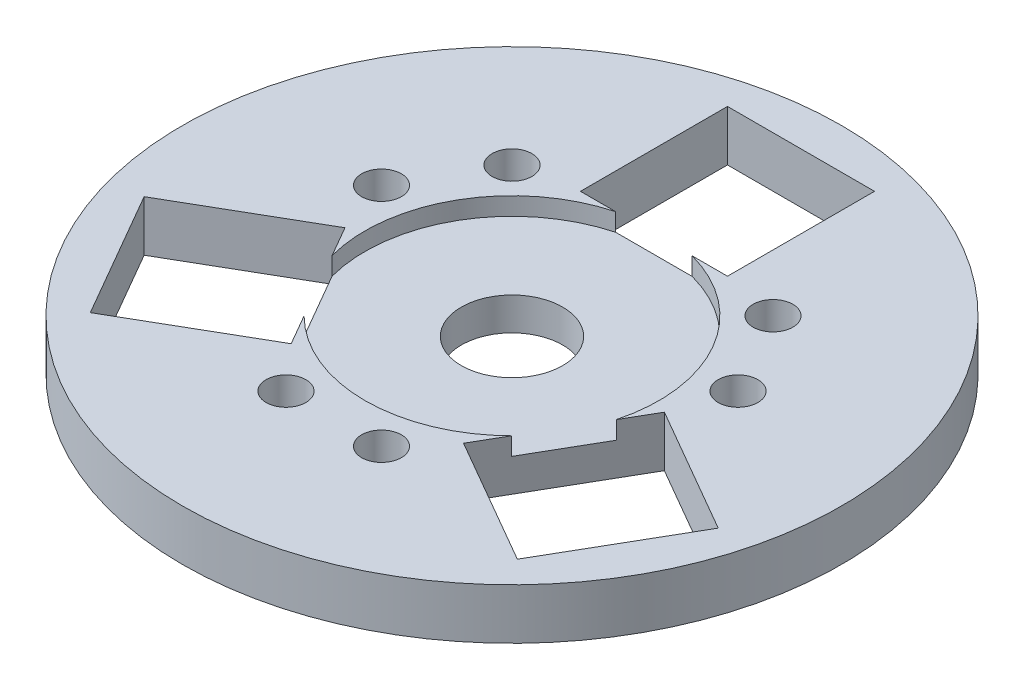
from build123d import *

# Parameters (mm, degrees)
SKETCH1_R           = 44.45
SKETCH1_R_2         = 6.35
BOSS_EXTRUDE1_DEPTH = 3.175
SKETCH5_W           = 18.415
SKETCH5_H           = 18.415
CUT_EXTRUDE4_DEPTH  = 64.181702256
CIRPATTERN2_COUNT   = 3
SKETCH3_R           = 44.45
SKETCH3_R_2         = 41.275
CUT_EXTRUDE2_DEPTH  = 64.181702256
SKETCH6_R           = 18.415
CUT_EXTRUDE5_DEPTH  = 2.2352
SKETCH7_R           = 2.4892
CUT_EXTRUDE6_DEPTH  = 59.716043378
CIRPATTERN3_COUNT   = 3


with BuildPart() as part:
    # Sketch1 → Boss-Extrude1 (new, symmetric)
    with BuildSketch(Plane(origin=(0, 0, 0), x_dir=(1, 0, 0), z_dir=(0, 1, 0))):
        with Locations(Location((0, 0, 0), (0, 0, 270))):
            Circle(SKETCH1_R)
        with Locations(Location((0, 0, 0), (0, 0, 270))):
            Circle(SKETCH1_R_2, mode=Mode.SUBTRACT)
    extrude(amount=BOSS_EXTRUDE1_DEPTH, both=True)

    # Sketch5 → Cut-Extrude4 (cut, through all)
    with BuildSketch(Plane(origin=(0, 3.175, 0), x_dir=(1, 0, 0), z_dir=(0, 1, 0))):
        with Locations((0, 26.9875)):
            Rectangle(SKETCH5_W, SKETCH5_H)
    cut_extrude4 = extrude(amount=-CUT_EXTRUDE4_DEPTH, mode=Mode.SUBTRACT)

    # CirPattern2: Cut-Extrude4 ×3 about axis
    cirpattern2_axis = Axis((0, 0, 0), (0, 1, 0))
    for i in range(1, CIRPATTERN2_COUNT):
        add(cut_extrude4.rotate(cirpattern2_axis, i * 360 / CIRPATTERN2_COUNT), mode=Mode.SUBTRACT)

    # Sketch3 → Cut-Extrude2 (cut, through all)
    with BuildSketch(Plane(origin=(0, 3.175, 0), x_dir=(1, 0, 0), z_dir=(0, 1, 0))):
        Circle(SKETCH3_R)
        with Locations(Location((0, 0, 0), (0, 0, 270))):
            Circle(SKETCH3_R_2, mode=Mode.SUBTRACT)
    extrude(amount=-CUT_EXTRUDE2_DEPTH, mode=Mode.SUBTRACT)

    # Sketch6 → Cut-Extrude5 (cut)
    with BuildSketch(Plane(origin=(0, 3.175, 0), x_dir=(1, 0, 0), z_dir=(0, 1, 0))):
        Circle(SKETCH6_R)
    extrude(amount=-CUT_EXTRUDE5_DEPTH, mode=Mode.SUBTRACT)

    # Sketch7 → Cut-Extrude6 (cut, through all)
    with BuildSketch(Plane(origin=(0, 3.175, 0), x_dir=(1, 0, 0), z_dir=(0, 1, 0))):
        with Locations(Location((-16.34406614, 16.34406614, 0), (0, 0, 270))):
            Circle(SKETCH7_R)
        with Locations(Location((-22.326409549, 5.982343408, 0), (0, 0, 270))):
            Circle(SKETCH7_R)
    cut_extrude6 = extrude(amount=-CUT_EXTRUDE6_DEPTH, mode=Mode.SUBTRACT)

    # CirPattern3: Cut-Extrude6 ×3 about axis
    cirpattern3_axis = Axis((0, 0, 0), (0, 1, 0))
    for i in range(1, CIRPATTERN3_COUNT):
        add(cut_extrude6.rotate(cirpattern3_axis, i * 360 / CIRPATTERN3_COUNT), mode=Mode.SUBTRACT)


solid = part.part
